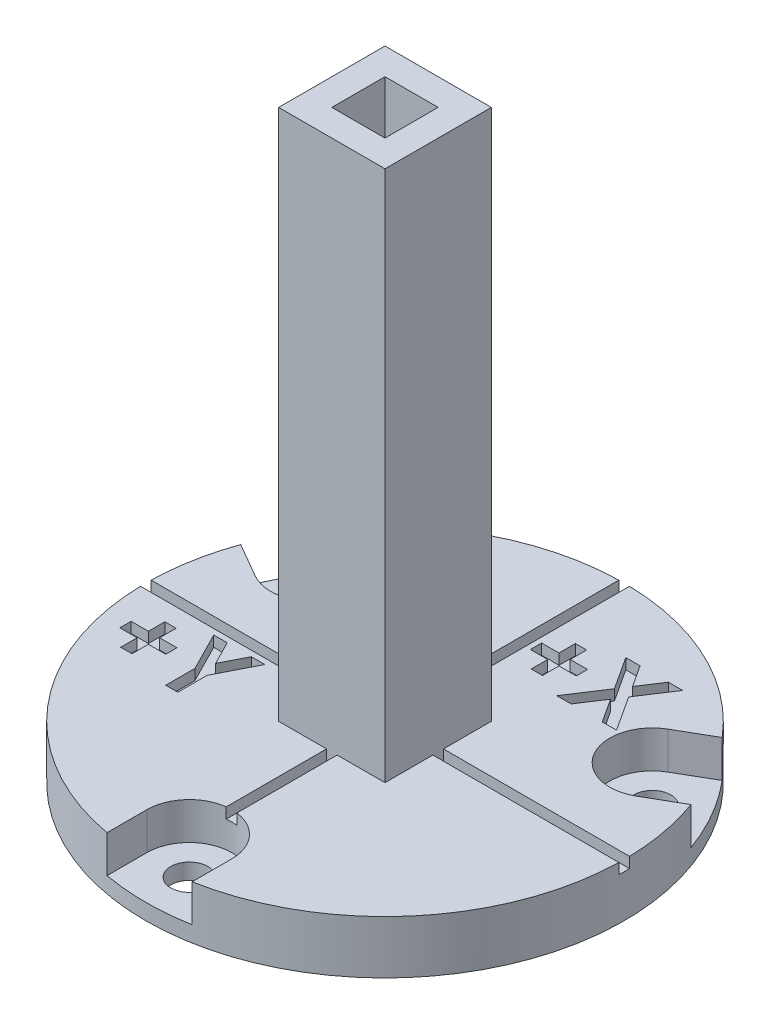
from build123d import *

# Parameters (mm, degrees)
SKETCH1_R                     = 22.5
PLATE_DEPTH                   = 5
OPENING_START                 = 1.5
OPENING_FOR_SCREW_DEPTH       = 5
SKETCH7_R                     = 1.75
SCREW_HOLE_DEPTH              = 5
CIRPATTERN20_COUNT            = 3
SKETCH10_W                    = 45
SKETCH10_H                    = 1
SKETCH10_W_2                  = 1
SKETCH10_H_2                  = 45
CUT_EXTRUDE5_DEPTH            = 1
CUT_EXTRUDE6_DEPTH            = 1
SKETCH12_W                    = 10
SKETCH12_H                    = 10
SKETCH12_W_2                  = 5
SKETCH12_H_2                  = 5
TOOL_CONNECT_PIECE_DEPTH      = 50
TOOL_CONNECT_PIECE_DEPTH_BACK = 1


with BuildPart() as part:
    # Sketch1 → plate (new body)
    with BuildSketch(Plane(origin=(0, 0, 0), x_dir=(1, 0, 0), z_dir=(0, 1, 0))):
        Circle(SKETCH1_R)
    extrude(amount=PLATE_DEPTH)

    # Sketch6 → opening for screw (cut)
    with BuildSketch(Plane(origin=(0, 5, 0), x_dir=(1, 0, 0), z_dir=(0, 1, 0)).offset(OPENING_START)):
        with BuildLine():
            Line((-4, -22.5), (-4, -18.4))
            ThreePointArc((-4, -18.4), (0, -14.4), (4, -18.4))
            Line((4, -18.4), (4, -22.5))
            ThreePointArc((4, -22.5), (0, -26.5), (-4, -22.5))
        make_face()
    opening_for_screw = extrude(amount=-OPENING_FOR_SCREW_DEPTH, mode=Mode.SUBTRACT)

    # Sketch7 → screw hole (cut)
    with BuildSketch(Plane(origin=(0, 1.5, 0), x_dir=(1, 0, 0), z_dir=(0, 1, 0))):
        with Locations((0, -18.4)):
            Circle(SKETCH7_R)
    screw_hole = extrude(amount=-SCREW_HOLE_DEPTH, mode=Mode.SUBTRACT)

    # CirPattern20: opening for screw, screw hole ×3 about axis
    cirpattern20_axis = Axis((0, 0, 0), (0, 1, 0))
    for i in range(1, CIRPATTERN20_COUNT):
        add(opening_for_screw.rotate(cirpattern20_axis, i * 360 / CIRPATTERN20_COUNT), mode=Mode.SUBTRACT)
        add(screw_hole.rotate(cirpattern20_axis, i * 360 / CIRPATTERN20_COUNT), mode=Mode.SUBTRACT)

    # Sketch10 → Cut-Extrude5 (cut)
    with BuildSketch(Plane(origin=(0, 5, 0), x_dir=(1, 0, 0), z_dir=(0, 1, 0))):
        Rectangle(SKETCH10_W, SKETCH10_H)
        Rectangle(SKETCH10_W_2, SKETCH10_H_2)
    extrude(amount=-CUT_EXTRUDE5_DEPTH, mode=Mode.SUBTRACT)

    # Sketch11 → Cut-Extrude6 (cut)
    with BuildSketch(Plane(origin=(0, 5, 0), x_dir=(1, 0, 0), z_dir=(0, 1, 0))):
        Polygon((2.616666667, 13.742425761), (2.616666667, 15.289220632), (3.675, 15.289220632), (3.675, 13.742425761), (5.303205128, 13.742425761), (5.303205128, 12.684092427), (3.675, 12.684092427), (3.675, 11.137297556), (2.616666667, 11.137297556), (2.616666667, 12.684092427), (0.988461538, 12.684092427), (0.988461538, 13.742425761), align=None)
        Polygon((6.136388221, 16.510374479), (7.479657452, 16.510374479), (8.806390224, 14.471301963), (10.135667067, 16.510374479), (11.480208333, 16.510374479), (9.47802484, 13.43968137), (11.6125, 10.160374479), (10.269230769, 10.160374479), (8.806390224, 12.409332812), (7.339733574, 10.160374479), (5.995192308, 10.160374479), (8.134755609, 13.440953405), align=None)
        Polygon((-18.458103671, -3.794817635), (-18.458103671, -2.248022763), (-17.399770338, -2.248022763), (-17.399770338, -3.794817635), (-15.771565209, -3.794817635), (-15.771565209, -4.853150968), (-17.399770338, -4.853150968), (-17.399770338, -6.39994584), (-18.458103671, -6.39994584), (-18.458103671, -4.853150968), (-20.086308799, -4.853150968), (-20.086308799, -3.794817635), align=None)
        Polygon((-15.07957803, -1.026868917), (-13.811358879, -1.026868917), (-12.677975466, -3.254202651), (-11.544592052, -1.026868917), (-10.276372902, -1.026868917), (-12.108103671, -4.626728693), (-12.108103671, -7.376868917), (-13.247847261, -7.376868917), (-13.247847261, -4.626728693), align=None)
    extrude(amount=-CUT_EXTRUDE6_DEPTH, mode=Mode.SUBTRACT)

    # Sketch12 → tool connect piece (add, two sides)
    with BuildSketch(Plane(origin=(0, 5, 0), x_dir=(1, 0, 0), z_dir=(0, 1, 0))) as tool_connect_piece_sk:
        Rectangle(SKETCH12_W, SKETCH12_H)
        Rectangle(SKETCH12_W_2, SKETCH12_H_2, mode=Mode.SUBTRACT)
    extrude(amount=TOOL_CONNECT_PIECE_DEPTH)
    extrude(tool_connect_piece_sk.sketch, amount=-TOOL_CONNECT_PIECE_DEPTH_BACK)


solid = part.part
